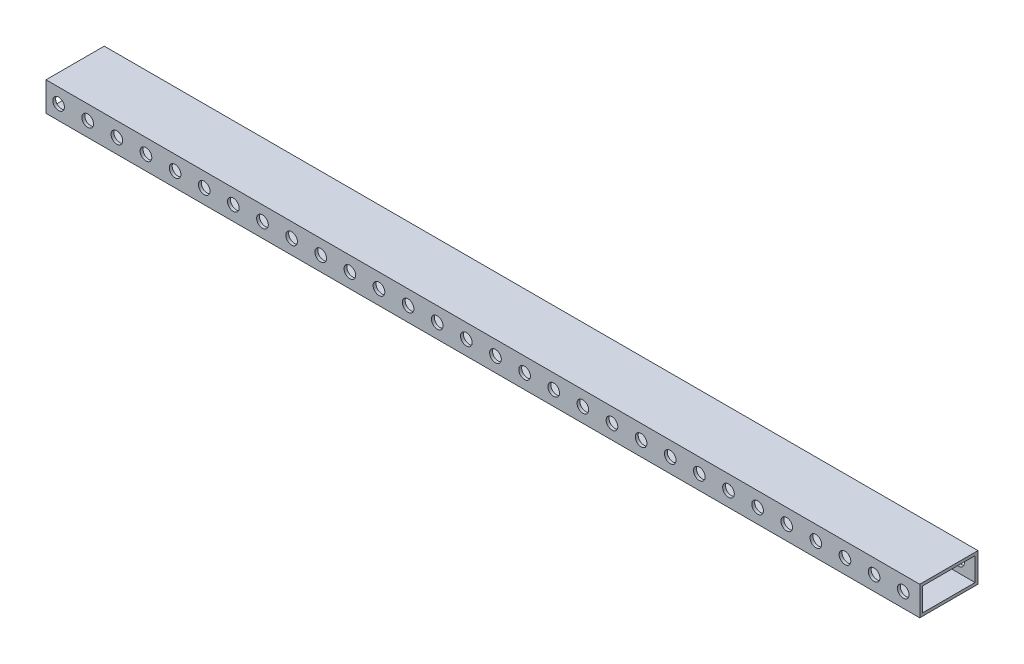
from build123d import *

# Parameters (mm, degrees)
SKETCH3_W           = 50.8
SKETCH3_H           = 25.4
SKETCH3_W_2         = 45.72
SKETCH3_H_2         = 20.32
BOSS_EXTRUDE1_DEPTH = 762
SKETCH5_R           = 5.08
CUT_EXTRUDE2_DEPTH  = 127
SKETCH5_8_R         = 5.08
CUT_EXTRUDE5_DEPTH  = 127
SKETCH5_9_R         = 5.08
CUT_EXTRUDE6_DEPTH  = 127


with BuildPart() as part:
    # Sketch3 → Boss-Extrude1 (new body)
    with BuildSketch(Plane(origin=(0, 0, 0), x_dir=(0, 0, -1), z_dir=(1, 0, 0))):
        with Locations((5.321216632, -1.999606833)):
            Rectangle(SKETCH3_W, SKETCH3_H)
        with Locations((5.321216632, -1.999606833)):
            Rectangle(SKETCH3_W_2, SKETCH3_H_2, mode=Mode.SUBTRACT)
    extrude(amount=BOSS_EXTRUDE1_DEPTH)

    # Sketch5 → Cut-Extrude2 (cut)
    with BuildSketch(Plane.XY.offset(20.078783368)):
        with Locations((10.978833808, -1.999606833)):
            Circle(SKETCH5_R)
        with Locations((36.378833808, -1.999606833)):
            Circle(SKETCH5_R)
        with Locations((61.778833808, -1.999606833)):
            Circle(SKETCH5_R)
        with Locations((87.178833808, -1.999606833)):
            Circle(SKETCH5_R)
        with Locations((112.578833808, -1.999606833)):
            Circle(SKETCH5_R)
        with Locations((137.978833808, -1.999606833)):
            Circle(SKETCH5_R)
        with Locations((163.378833808, -1.999606833)):
            Circle(SKETCH5_R)
        with Locations((188.778833808, -1.999606833)):
            Circle(SKETCH5_R)
        with Locations((214.178833808, -1.999606833)):
            Circle(SKETCH5_R)
        with Locations((239.578833808, -1.999606833)):
            Circle(SKETCH5_R)
        with Locations((264.978833808, -1.999606833)):
            Circle(SKETCH5_R)
        with Locations((290.378833808, -1.999606833)):
            Circle(SKETCH5_R)
        with Locations((315.778833808, -1.999606833)):
            Circle(SKETCH5_R)
        with Locations((341.178833808, -1.999606833)):
            Circle(SKETCH5_R)
        with Locations((366.578833808, -1.999606833)):
            Circle(SKETCH5_R)
        with Locations((391.978833808, -1.999606833)):
            Circle(SKETCH5_R)
        with Locations((417.378833808, -1.999606833)):
            Circle(SKETCH5_R)
        with Locations((442.778833808, -1.999606833)):
            Circle(SKETCH5_R)
        with Locations((468.178833808, -1.999606833)):
            Circle(SKETCH5_R)
        with Locations((493.578833808, -1.999606833)):
            Circle(SKETCH5_R)
        with Locations((518.978833808, -1.999606833)):
            Circle(SKETCH5_R)
        with Locations((544.378833808, -1.999606833)):
            Circle(SKETCH5_R)
        with Locations((569.778833808, -1.999606833)):
            Circle(SKETCH5_R)
        with Locations((595.178833808, -1.999606833)):
            Circle(SKETCH5_R)
        with Locations((620.578833808, -1.999606833)):
            Circle(SKETCH5_R)
        with Locations((645.978833808, -1.999606833)):
            Circle(SKETCH5_R)
        with Locations((671.378833808, -1.999606833)):
            Circle(SKETCH5_R)
        with Locations((696.778833808, -1.999606833)):
            Circle(SKETCH5_R)
    extrude(amount=-CUT_EXTRUDE2_DEPTH, mode=Mode.SUBTRACT)

    # Sketch5_8 → Cut-Extrude5 (cut)
    with BuildSketch(Plane.XY.offset(20.078783368)):
        with Locations((722.178833808, -1.999606833)):
            Circle(SKETCH5_8_R)
    extrude(amount=-CUT_EXTRUDE5_DEPTH, mode=Mode.SUBTRACT)

    # Sketch5_9 → Cut-Extrude6 (cut)
    with BuildSketch(Plane.XY.offset(20.078783368)):
        with Locations((747.578833808, -1.999606833)):
            Circle(SKETCH5_9_R)
    extrude(amount=-CUT_EXTRUDE6_DEPTH, mode=Mode.SUBTRACT)


solid = part.part
